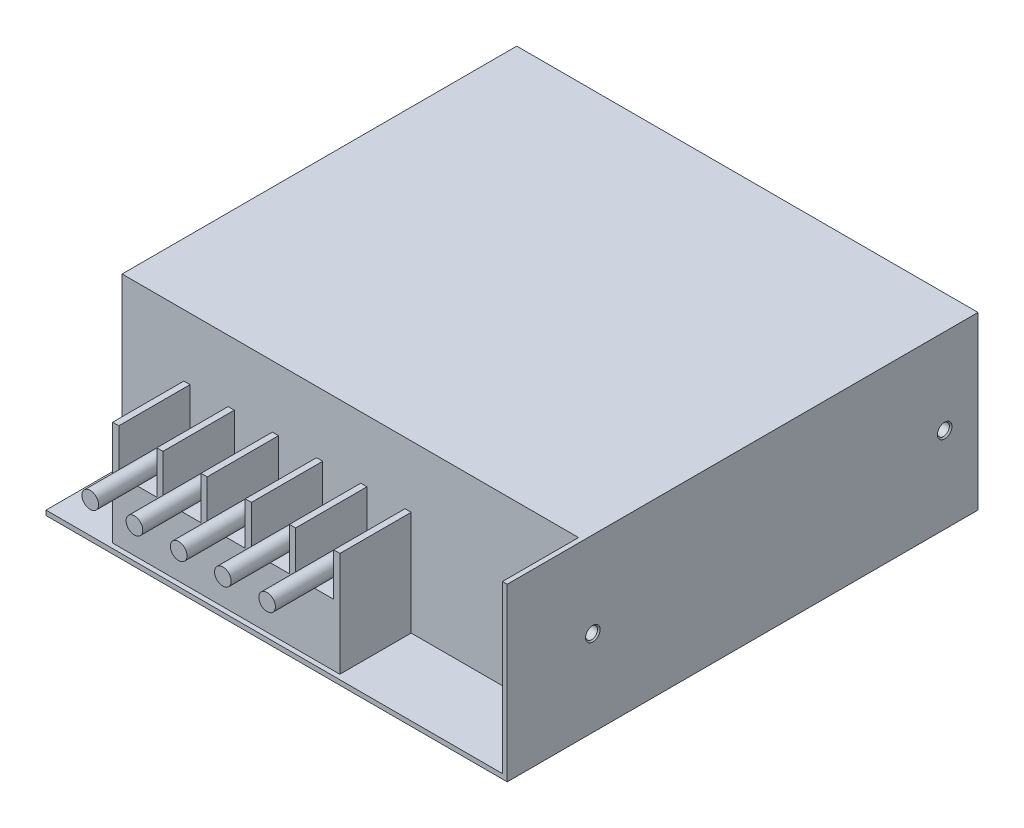
from build123d import *

# Parameters (mm, degrees)
SKETCH1_W                   = 97
SKETCH1_H                   = 99
BOSS_EXTRUDE1_DEPTH         = 36
SKETCH2_W                   = 96
SKETCH2_H                   = 35
CUT_EXTRUDE1_DEPTH          = 16
BOSS_EXTRUDE2_DEPTH         = 15
SKETCH4_R                   = 1.75
BOSS_EXTRUDE3_DEPTH         = 25
M3_TAPPED_HOLE1_D           = 2.5
M3_TAPPED_HOLE1_DEPTH       = 4.5
M3_TAPPED_HOLE1_CSINK_D     = 3.05
M3_TAPPED_HOLE1_CSINK_ANGLE = 90
M3_TAPPED_HOLE1_TIP         = 0.751075774
M3_TAPPED_HOLE2_D           = 2.5
M3_TAPPED_HOLE2_DEPTH       = 4.5
M3_TAPPED_HOLE2_CSINK_D     = 3.05
M3_TAPPED_HOLE2_CSINK_ANGLE = 90
M3_TAPPED_HOLE2_TIP         = 0.751075774


with BuildPart() as part:
    # Sketch1 → Boss-Extrude1 (new body)
    with BuildSketch(Plane(origin=(0, 0, 0), x_dir=(1, 0, 0), z_dir=(0, 1, 0))):
        Rectangle(SKETCH1_W, SKETCH1_H)
    extrude(amount=BOSS_EXTRUDE1_DEPTH)

    # Sketch2 → Cut-Extrude1 (cut)
    with BuildSketch(Plane.XY.offset(49.5)):
        with Locations((-0.5, 18.5)):
            Rectangle(SKETCH2_W, SKETCH2_H)
    extrude(amount=-CUT_EXTRUDE1_DEPTH, mode=Mode.SUBTRACT)

    # Sketch3 → Boss-Extrude2 (add)
    with BuildSketch(Plane.XY.offset(33.5)):
        Polygon((-35.5, 1), (12.3, 1), (12.3, 23), (11, 23), (11, 14), (3, 14), (3, 23), (1.7, 23), (1.7, 14), (-6.3, 14), (-6.3, 23), (-7.6, 23), (-7.6, 14), (-15.6, 14), (-15.6, 23), (-16.9, 23), (-16.9, 14), (-24.9, 14), (-24.9, 23), (-26.2, 23), (-26.2, 14), (-34.2, 14), (-34.2, 23), (-35.5, 23), align=None)
    extrude(amount=BOSS_EXTRUDE2_DEPTH)

    # Sketch4 → Boss-Extrude3 (add)
    with BuildSketch(Plane.XY.offset(33.5)):
        with Locations((-30.2, 16.5)):
            Circle(SKETCH4_R)
        with Locations((-20.9, 16.5)):
            Circle(SKETCH4_R)
        with Locations((-11.6, 16.5)):
            Circle(SKETCH4_R)
        with Locations((-2.3, 16.5)):
            Circle(SKETCH4_R)
        with Locations((7, 16.5)):
            Circle(SKETCH4_R)
    extrude(amount=BOSS_EXTRUDE3_DEPTH)

    # M3 Tapped Hole1
    with Locations(Plane(origin=(48.5, 0, 0), x_dir=(0, 0, -1), z_dir=(1, 0, 0))):
        with Locations((-31.5, 18), (42.5, 18)):
            CounterSinkHole(M3_TAPPED_HOLE1_D / 2, M3_TAPPED_HOLE1_CSINK_D / 2, depth=M3_TAPPED_HOLE1_DEPTH, counter_sink_angle=M3_TAPPED_HOLE1_CSINK_ANGLE)
            with Locations((0, 0, -(M3_TAPPED_HOLE1_DEPTH + M3_TAPPED_HOLE1_TIP / 2))):  # 118° drill point
                Cone(0, M3_TAPPED_HOLE1_D / 2, M3_TAPPED_HOLE1_TIP, mode=Mode.SUBTRACT)

    # M3 Tapped Hole2
    with Locations(Plane(origin=(0, 0, 0), x_dir=(-1, 0, 0), z_dir=(0, -1, 0))):
        with Locations((-3, -29), (-3, 26)):
            CounterSinkHole(M3_TAPPED_HOLE2_D / 2, M3_TAPPED_HOLE2_CSINK_D / 2, depth=M3_TAPPED_HOLE2_DEPTH, counter_sink_angle=M3_TAPPED_HOLE2_CSINK_ANGLE)
            with Locations((0, 0, -(M3_TAPPED_HOLE2_DEPTH + M3_TAPPED_HOLE2_TIP / 2))):  # 118° drill point
                Cone(0, M3_TAPPED_HOLE2_D / 2, M3_TAPPED_HOLE2_TIP, mode=Mode.SUBTRACT)


solid = part.part
